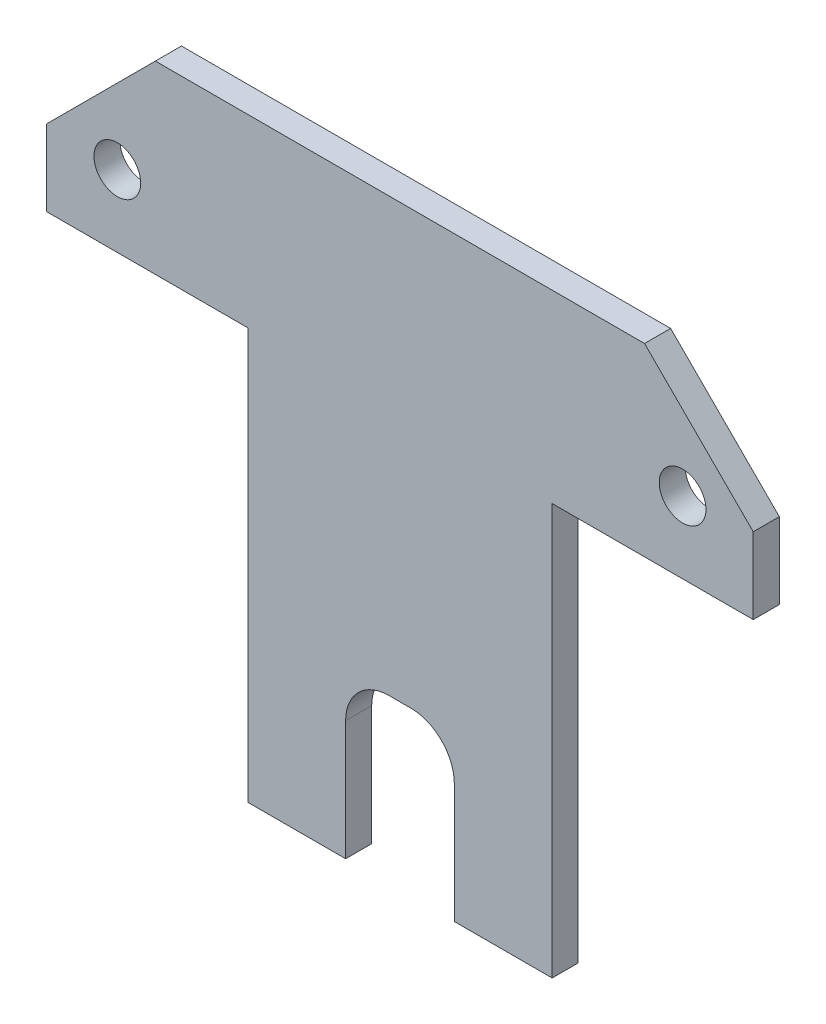
from build123d import *

# Parameters (mm, degrees)
SKETCH1_R           = 2.15
BOSS_EXTRUDE1_DEPTH = 2.4
SKETCH2_W           = 10
SKETCH2_H           = 30
CUT_EXTRUDE1_DEPTH  = 3.4
FILLET1_R           = 4


with BuildPart() as part:
    # Sketch1 → Boss-Extrude1 (new body)
    with BuildSketch(Plane.XY):
        Polygon((-21.105584483, 33.074652619), (23.894415517, 33.074652619), (33.894415517, 23.074652619), (33.894415517, 16.074652619), (15.394415517, 16.074652619), (15.394415517, -21.725347381), (-12.605584483, -21.725347381), (-12.605584483, 16.074652619), (-31.105584483, 16.074652619), (-31.105584483, 23.074652619), align=None)
        with Locations((-24.605584483, 22.674652619)):
            Circle(SKETCH1_R, mode=Mode.SUBTRACT)
        with Locations((27.394415517, 22.674652619)):
            Circle(SKETCH1_R, mode=Mode.SUBTRACT)
    extrude(amount=BOSS_EXTRUDE1_DEPTH)

    # Sketch2 → Cut-Extrude1 (cut, through all)
    with BuildSketch(Plane.XY.offset(2.4)):
        with Locations((1.394415517, -21.725347381)):
            Rectangle(SKETCH2_W, SKETCH2_H)
    extrude(amount=-CUT_EXTRUDE1_DEPTH, mode=Mode.SUBTRACT)

    # Fillet1
    fillet1_edges = [part.edges().sort_by_distance(p)[0] for p in [
        (6.394415517, -6.725347381, 1.2),
        (-3.605584483, -6.725347381, 1.2),
    ]]
    fillet(fillet1_edges, radius=FILLET1_R)


solid = part.part
